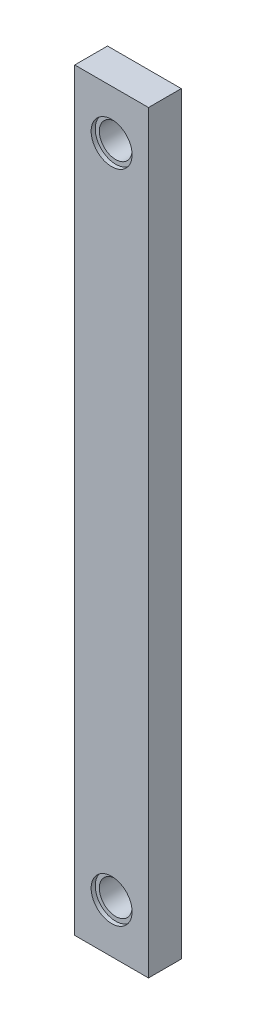
from build123d import *

# Parameters (mm, degrees)
SKETCH2_W           = 28.575
SKETCH2_H           = 292.1
BOSS_EXTRUDE1_DEPTH = 6.35
SKETCH4_R           = 6.35
CUT_EXTRUDE1_DEPTH  = 7.35
SKETCH5_R           = 7.9375
CUT_EXTRUDE2_DEPTH  = 1.5875


with BuildPart() as part:
    # Sketch2 → Boss-Extrude1 (new body, symmetric)
    with BuildSketch(Plane.XY):
        with Locations((0, 127)):
            Rectangle(SKETCH2_W, SKETCH2_H)
    extrude(amount=BOSS_EXTRUDE1_DEPTH, both=True)

    # Sketch4 → Cut-Extrude1 (cut, symmetric)
    with BuildSketch(Plane.XY):
        Circle(SKETCH4_R)
    cut_extrude1 = extrude(amount=CUT_EXTRUDE1_DEPTH, both=True, mode=Mode.SUBTRACT)

    # Sketch5 → Cut-Extrude2 (cut)
    with BuildSketch(Plane.XY.offset(6.35)):
        Circle(SKETCH5_R)
    cut_extrude2 = extrude(amount=-CUT_EXTRUDE2_DEPTH, mode=Mode.SUBTRACT)

    # Mirror1: Cut-Extrude1, Cut-Extrude2 across plane
    add(cut_extrude1.mirror(Plane(origin=(0, 127, 0), x_dir=(0, 0, 1), z_dir=(0, -1, 0))), mode=Mode.SUBTRACT)
    add(cut_extrude2.mirror(Plane(origin=(0, 127, 0), x_dir=(0, 0, 1), z_dir=(0, -1, 0))), mode=Mode.SUBTRACT)


solid = part.part
